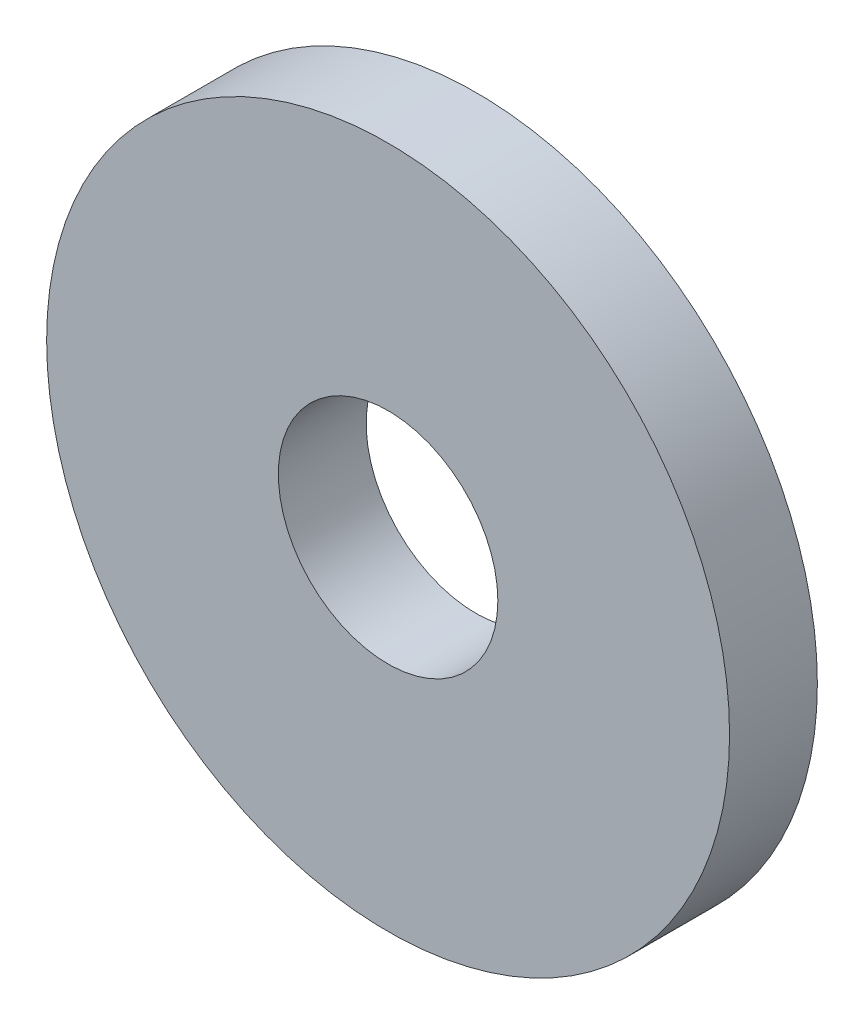
from build123d import *

# Parameters (mm, degrees)
SKETCH1_R           = 14
SKETCH1_R_2         = 4.5
BOSS_EXTRUDE1_DEPTH = 3.6


with BuildPart() as part:
    # Sketch1 → Boss-Extrude1 (new body)
    with BuildSketch(Plane.XY):
        Circle(SKETCH1_R)
        Circle(SKETCH1_R_2, mode=Mode.SUBTRACT)
    extrude(amount=BOSS_EXTRUDE1_DEPTH)


solid = part.part
